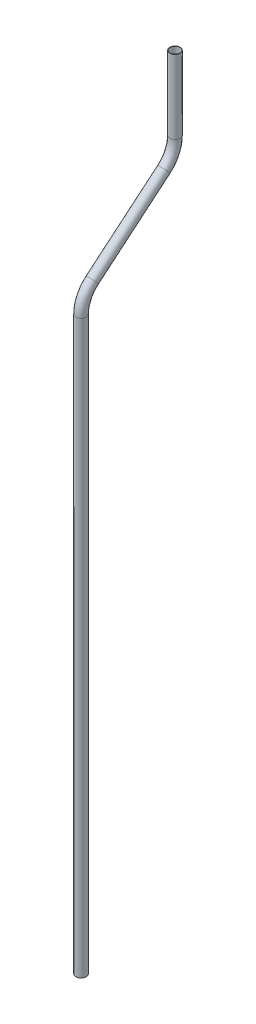
from build123d import *

# Parameters (mm, degrees)
SKETCH1_R   = 6.35
SKETCH1_R_2 = 5.969


with BuildPart() as part:
    # Sweep2: sweep along a path in Sketch2
    with BuildLine(Plane(origin=(0, 0, 0), x_dir=(0, 0, -1), z_dir=(1, 0, 0))) as sweep2_path:
        Line((0, 0), (0, 698.5))
        ThreePointArc((0, 698.5), (3.569673314, 714.601755772), (13.609792071, 727.686293283))
        Line((13.609792071, 727.686293283), (101.168671919, 801.15691707))
        ThreePointArc((101.168671919, 801.15691707), (111.208790676, 814.241454581), (114.77846399, 830.343210353))
        Line((114.77846399, 830.343210353), (114.77846399, 920.513210353))
    # Sketch1 → Sweep2 (sweep)
    with BuildSketch(Plane(origin=(0, 0, 0), x_dir=(1, 0, 0), z_dir=(0, 1, 0))):
        Circle(SKETCH1_R)
        Circle(SKETCH1_R_2, mode=Mode.SUBTRACT)
    sweep(path=sweep2_path.line)


solid = part.part
